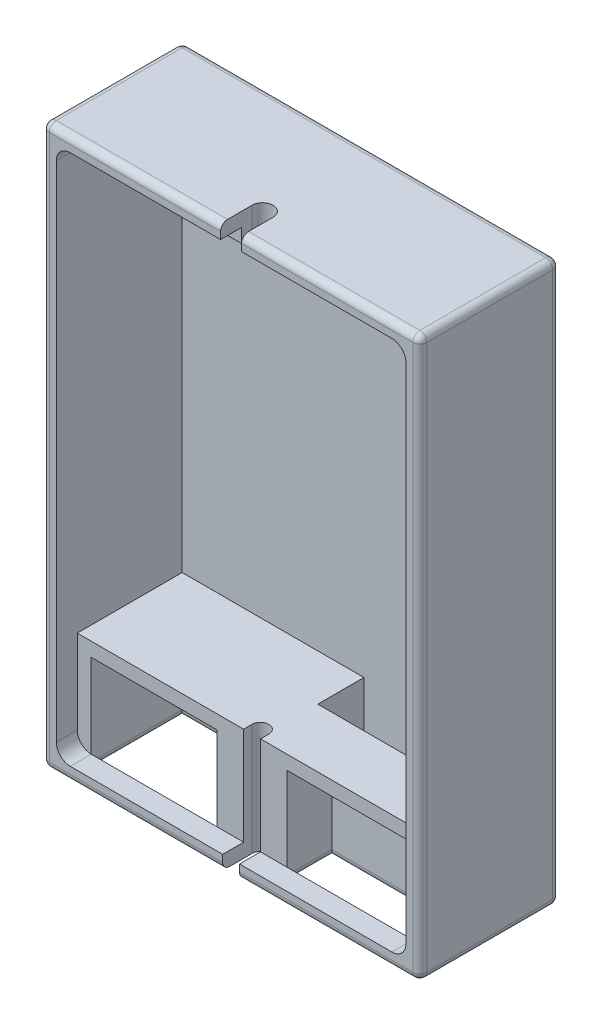
from build123d import *

# Parameters (mm, degrees)
SKETCH_2_W           = 27
SKETCH_2_H           = 40
EXTRUDE_1_DEPTH      = 10
CUT_EXTRUDE_1_DEPTH  = 1.5
CUT_EXTRUDE_2_DEPTH  = 7.5
SKETCH_9_W           = 9
SKETCH_9_H           = 4.718038217
CUT_EXTRUDE_8_DEPTH  = 3.2
SKETCH_9_3_W         = 9
SKETCH_9_3_H         = 4.718038217
CUT_EXTRUDE_9_DEPTH  = 6.5
SKETCH_12_W          = 12
SKETCH_12_H          = 3.3
CUT_EXTRUDE_10_DEPTH = 7
SKETCH_13_W          = 9
SKETCH_13_H          = 6.5
SKETCH_13_H_2        = 3.2
CUT_EXTRUDE_11_DEPTH = 3.281961783
CUT_EXTRUDE_12_REACH = 42
SKETCH_14_W          = 1.2
SKETCH_14_H          = 2.1
SKETCH_16_2_W        = 7
SKETCH_16_2_H        = 2.5
EXTRUDE_3_DEPTH      = 1
SKETCH_16_W          = 7
SKETCH_16_H          = 2.5
EXTRUDE_2_DEPTH      = 1
CUT_EXTRUDE_14_DEPTH = 2
FILLET_1_R           = 0.5


with BuildPart() as part:
    # Sketch 2 → Extrude 1 (new body)
    with BuildSketch(Plane.XY):
        with Locations((13.5, 20)):
            Rectangle(SKETCH_2_W, SKETCH_2_H)
    extrude(amount=EXTRUDE_1_DEPTH)

    # Sketch 3 → Cut-Extrude 1 (cut)
    with BuildSketch(Plane.XY.offset(10)):
        with BuildLine():
            Line((1, 38), (1, 2))
            ThreePointArc((1, 2), (1.292893219, 1.292893219), (2, 1))
            Line((2, 1), (25, 1))
            ThreePointArc((25, 1), (25.707106781, 1.292893219), (26, 2))
            Line((26, 2), (26, 38))
            ThreePointArc((26, 38), (25.707106781, 38.707106781), (25, 39))
            Line((25, 39), (2, 39))
            ThreePointArc((2, 39), (1.292893219, 38.707106781), (1, 38))
        make_face()
    extrude(amount=-CUT_EXTRUDE_1_DEPTH, mode=Mode.SUBTRACT)

    # Sketch 5 → Cut-Extrude 2 (cut)
    with BuildSketch(Plane.XY.offset(8.5)):
        with BuildLine():
            Line((2, 39), (25, 39))
            ThreePointArc((25, 39), (25.707106781, 38.707106781), (26, 38))
            Line((26, 38), (26, 8))
            Line((26, 8), (1, 8))
            Line((1, 8), (1, 38))
            ThreePointArc((1, 38), (1.292893219, 38.707106781), (2, 39))
        make_face()
    extrude(amount=-CUT_EXTRUDE_2_DEPTH, mode=Mode.SUBTRACT)

    # Sketch 9 → Cut-Extrude 8 (cut)
    with BuildSketch(Plane.XY.offset(8.5)):
        with Locations((20.5, 4.640980891)):
            Rectangle(SKETCH_9_W, SKETCH_9_H)
    extrude(amount=-CUT_EXTRUDE_8_DEPTH, mode=Mode.SUBTRACT)

    # Sketch 9_3 → Cut-Extrude 9 (cut)
    with BuildSketch(Plane.XY.offset(8.5)):
        with Locations((6.5, 4.640980891)):
            Rectangle(SKETCH_9_3_W, SKETCH_9_3_H)
    extrude(amount=-CUT_EXTRUDE_9_DEPTH, mode=Mode.SUBTRACT)

    # Sketch 12 → Cut-Extrude 10 (cut)
    with BuildSketch(Plane(origin=(0, 8, 0), x_dir=(1, 0, 0), z_dir=(0, 1, 0))):
        with Locations((20, -2.65)):
            Rectangle(SKETCH_12_W, SKETCH_12_H)
    extrude(amount=-CUT_EXTRUDE_10_DEPTH, mode=Mode.SUBTRACT)

    # Sketch 13 → Cut-Extrude 11 (cut, through all)
    with BuildSketch(Plane(origin=(0, 2.281961783, 0), x_dir=(1, 0, 0), z_dir=(0, 1, 0))):
        with Locations((6.5, -5.25)):
            Rectangle(SKETCH_13_W, SKETCH_13_H)
        with Locations((20.5, -6.9)):
            Rectangle(SKETCH_13_W, SKETCH_13_H_2)
    extrude(amount=-CUT_EXTRUDE_11_DEPTH, mode=Mode.SUBTRACT)

    # Sketch 14 → Cut-Extrude 12 (cut, up to next)
    with BuildSketch(Plane.XZ, mode=Mode.PRIVATE) as cut_extrude_12_sk1:
        with BuildLine():
            Line((12.9, 7.9), (14.1, 7.9))
            ThreePointArc((14.1, 7.9), (13.5, 7.3), (12.9, 7.9))
        make_face()
    cut_extrude_12_tool1 = extrude(cut_extrude_12_sk1.sketch, amount=-CUT_EXTRUDE_12_REACH, mode=Mode.PRIVATE) & part.part
    add(cut_extrude_12_tool1.solids().sort_by_distance((13.5, 0, 7.645352))[0], mode=Mode.SUBTRACT)
    # Sketch 14 → Cut-Extrude 12 (cut, up to next)
    with BuildSketch(Plane.XZ, mode=Mode.PRIVATE) as cut_extrude_12_sk2:
        with Locations((13.5, 8.95)):
            Rectangle(SKETCH_14_W, SKETCH_14_H)
    cut_extrude_12_tool2 = extrude(cut_extrude_12_sk2.sketch, amount=-CUT_EXTRUDE_12_REACH, mode=Mode.PRIVATE) & part.part
    add(cut_extrude_12_tool2.solids().sort_by_distance((13.5, 0, 8.95))[0], mode=Mode.SUBTRACT)

    # Sketch 16_2 → Extrude 3 (add)
    with BuildSketch(Plane.XZ.offset(-39)):
        with Locations((13.5, 7.25)):
            Rectangle(SKETCH_16_2_W, SKETCH_16_2_H)
    extrude(amount=EXTRUDE_3_DEPTH)

    # Sketch 16 → Extrude 2 (add)
    with BuildSketch(Plane.XZ.offset(-39)):
        with Locations((13.5, 7.25)):
            Rectangle(SKETCH_16_W, SKETCH_16_H)
    extrude(amount=EXTRUDE_2_DEPTH)

    # Sketch 17 → Cut-Extrude 14 (cut)
    with BuildSketch(Plane(origin=(0, 40, 0), x_dir=(1, 0, 0), z_dir=(0, 1, 0))):
        with BuildLine():
            Line((14.25, -7.75), (14.25, -10))
            Line((14.25, -10), (12.75, -10))
            Line((12.75, -10), (12.75, -7.75))
            ThreePointArc((12.75, -7.75), (13.5, -7), (14.25, -7.75))
        make_face()
    extrude(amount=-CUT_EXTRUDE_14_DEPTH, mode=Mode.SUBTRACT)

    # Fillet 1
    fillet_1_edges = [part.edges().sort_by_distance(p)[0] for p in [
        (27, 20, 10),
        (20.5, 0, 8.5),
        (25, 0, 6.9),
        (16, 0, 6.9),
        (20.5, 0, 5.3),
        (20.625, 40, 10),
        (20.55, 0, 10),
        (6.375, 40, 10),
        (0, 20, 10),
        (13.5, 40, 0),
        (27, 20, 0),
        (13.5, 0, 0),
        (0, 20, 0),
        (6.45, 0, 10),
        (0, 40, 5),
        (27, 40, 5),
        (27, 0, 5),
        (0, 0, 5),
        (6.5, 0, 8.5),
        (11, 0, 5.25),
        (2, 0, 5.25),
        (6.5, 0, 2),
    ]]
    fillet(fillet_1_edges, radius=FILLET_1_R)


solid = part.part
